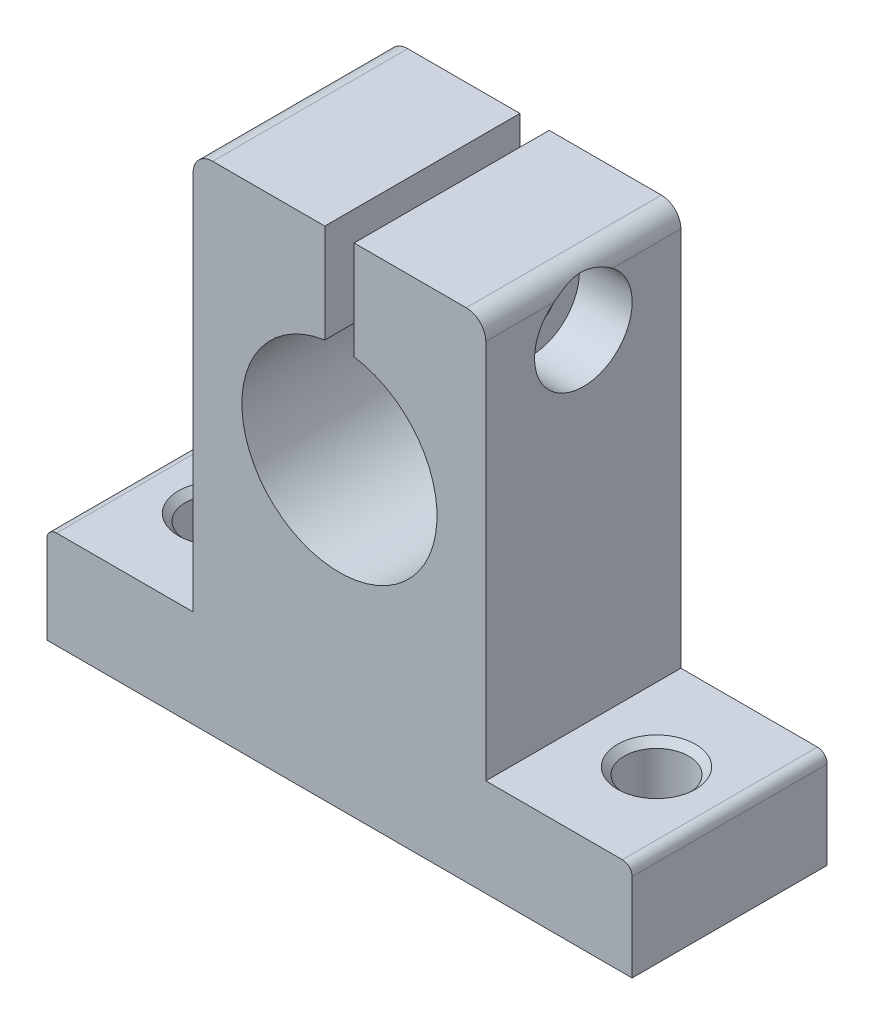
from build123d import *

# Parameters (mm, degrees)
BOSS_EXTRUDE1_DEPTH                                  = 20
CSK_FOR_M6_HEX_SOCKET_COUNTERSUNK_CAP_SC_D           = 6.6
CSK_FOR_M6_HEX_SOCKET_COUNTERSUNK_CAP_SC_CSINK_D     = 8
CSK_FOR_M6_HEX_SOCKET_COUNTERSUNK_CAP_SC_CSINK_ANGLE = 90
CBORE_FOR_M5_HEX_SOCKET_HEAD_CAP_SCREW1_D            = 5.5
CBORE_FOR_M5_HEX_SOCKET_HEAD_CAP_SCREW1_CBORE_D      = 10
CBORE_FOR_M5_HEX_SOCKET_HEAD_CAP_SCREW1_CBORE_DEPTH  = 5.4


with BuildPart() as part:
    # Sketch1 → Boss-Extrude1 (new body)
    with BuildSketch(Plane.XY):
        with BuildLine():
            Line((30, 0), (-30, 0))
            Line((-30, 0), (-30, 9))
            ThreePointArc((-30, 9), (-29.707106781, 9.707106781), (-29, 10))
            Line((-29, 10), (-15, 10))
            Line((-15, 10), (-15, 49))
            ThreePointArc((-15, 49), (-14.414213562, 50.414213562), (-13, 51))
            Line((-13, 51), (-1.5, 51))
            Line((-1.5, 51), (-1.5, 40.886859967))
            ThreePointArc((-1.5, 40.886859967), (0, 21), (1.5, 40.886859967))
            Line((1.5, 40.886859967), (1.5, 51))
            Line((1.5, 51), (13, 51))
            ThreePointArc((13, 51), (14.414213562, 50.414213562), (15, 49))
            Line((15, 49), (15, 10))
            Line((15, 10), (29, 10))
            ThreePointArc((29, 10), (29.707106781, 9.707106781), (30, 9))
            Line((30, 9), (30, 0))
        make_face()
    extrude(amount=BOSS_EXTRUDE1_DEPTH)

    # CSK for M6 Hex Socket Countersunk Cap Screw1 (through all)
    with Locations(Plane(origin=(-22.5, 10, 10), x_dir=(1, 0, 0), z_dir=(0, 1, 0))):
        with Locations((0, 0), (45, 0)):
            CounterSinkHole(CSK_FOR_M6_HEX_SOCKET_COUNTERSUNK_CAP_SC_D / 2, CSK_FOR_M6_HEX_SOCKET_COUNTERSUNK_CAP_SC_CSINK_D / 2, counter_sink_angle=CSK_FOR_M6_HEX_SOCKET_COUNTERSUNK_CAP_SC_CSINK_ANGLE)

    # CBORE for M5 Hex Socket Head Cap Screw1 (through all)
    with Locations(Plane(origin=(15, 45, 10), x_dir=(0, 0, 1), z_dir=(1, 0, 0))):
        with Locations((0, 0)):
            CounterBoreHole(CBORE_FOR_M5_HEX_SOCKET_HEAD_CAP_SCREW1_D / 2, CBORE_FOR_M5_HEX_SOCKET_HEAD_CAP_SCREW1_CBORE_D / 2, CBORE_FOR_M5_HEX_SOCKET_HEAD_CAP_SCREW1_CBORE_DEPTH)


solid = part.part
